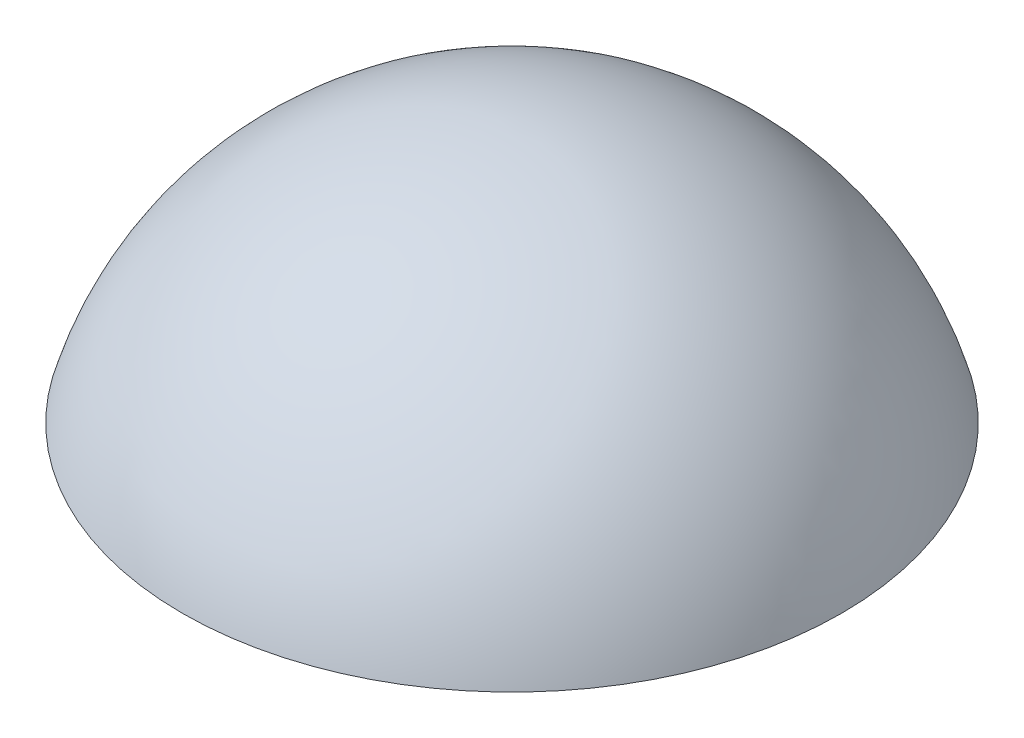
from build123d import *


with BuildPart() as part:
    # Sketch1 → Revolve1 (revolve)
    with BuildSketch(Plane.XY):
        with BuildLine():
            Line((0, 0), (-3.5, 0))
            ThreePointArc((-3.5, 0), (-2.195022779, 1.912765934), (0, 2.65))
            Line((0, 2.65), (0, 0))
        make_face()
    revolve(axis=Axis((0, 0, 0), (0, 1, 0)))


solid = part.part
